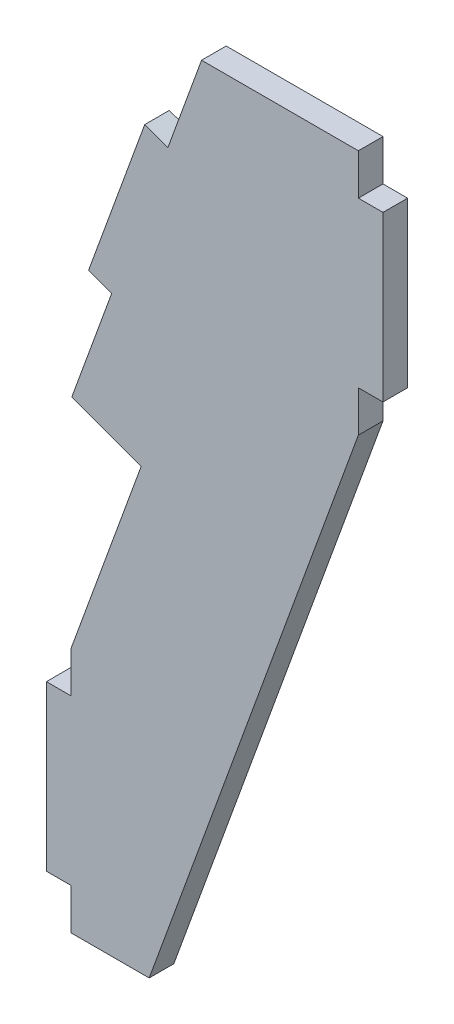
from build123d import *

# Parameters (mm, degrees)
BOSS_EXTRUDE1_DEPTH = 3
BOSS_EXTRUDE2_DEPTH = 3


with BuildPart() as part:
    # Sketch1 → Boss-Extrude1 (new body)
    with BuildSketch(Plane.XY):
        Polygon((3, -5), (12.522083602, -5), (38.000000001, 65), (38.000000001, 70), (41, 70), (41, 89.999999997), (38.000000001, 89.999999997), (38.000000001, 94.999999997), (28.477916397, 94.999999997), (18.390906449, 67.286167933), (15.571828589, 68.312228362), (8.731425723, 49.518375949), (11.550503583, 48.49231552), (3, 25), (3, 20), (0, 20), (0, 0), (3, 0), align=None)
    extrude(amount=BOSS_EXTRUDE1_DEPTH)

    # Sketch2 → Boss-Extrude2 (add)
    with BuildSketch(Plane(origin=(0, 0, 0), x_dir=(-1, 0, 0), z_dir=(0, 0, -1))):
        Polygon((-7.955671859, 64.929836131), (-3.093269996, 51.57049681), (-8.731425723, 49.518375949), (-15.571828589, 68.312228362), (-18.390906449, 67.286167933), (-28.477916397, 94.999999997), (-18.900316445, 94.999999997), (-14.796074725, 83.723688547), (-11.976996863, 84.749748977), (-5.136593996, 65.955896561), align=None)
    extrude(amount=-BOSS_EXTRUDE2_DEPTH)


solid = part.part
